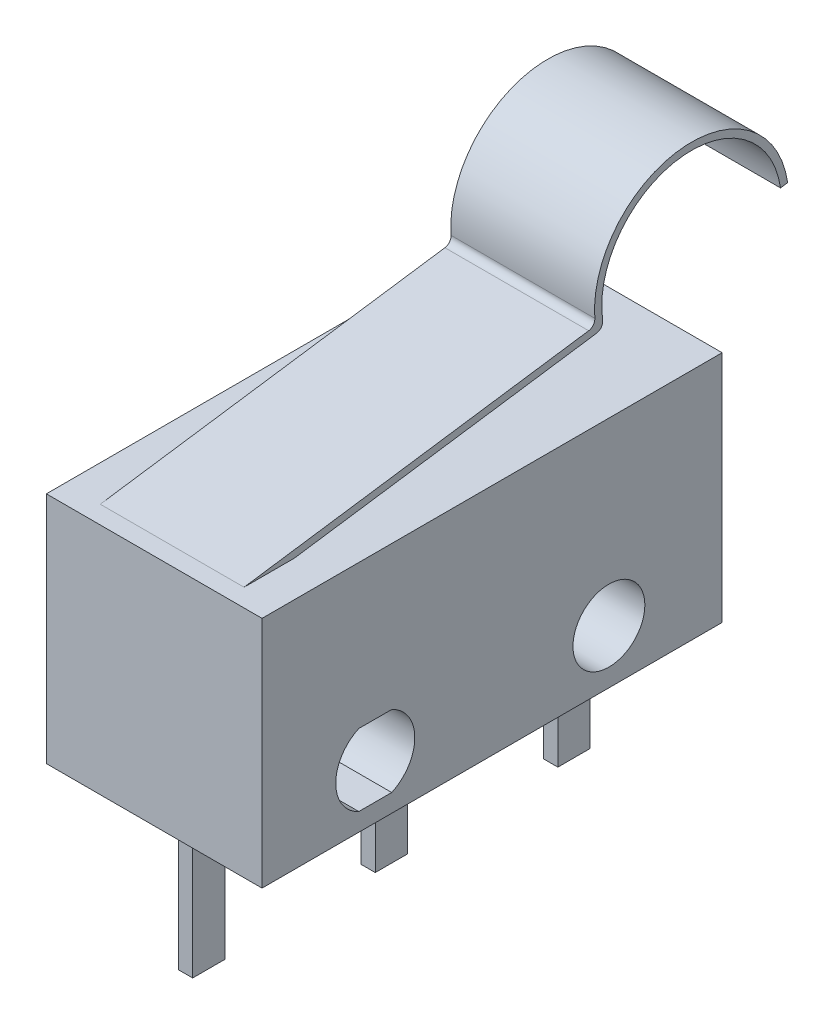
from build123d import *

# Parameters (mm, degrees)
SKETCH1_W           = 12.8
SKETCH1_H           = 6.5
SKETCH1_R           = 1
BOSS_EXTRUDE1_DEPTH = 3
SKETCH3_W           = 0.9
SKETCH3_H           = 4
BOSS_EXTRUDE2_DEPTH = 0.2
BOSS_EXTRUDE3_DEPTH = 2
FILLET1_R           = 0.2
BOSS_EXTRUDE5_DEPTH = 0.5


with BuildPart() as part:
    # Sketch1 → Boss-Extrude1 (new body, symmetric)
    with BuildSketch(Plane(origin=(0, 0, 0), x_dir=(0, 0, -1), z_dir=(1, 0, 0))):
        Rectangle(SKETCH1_W, SKETCH1_H)
        with Locations((3.25, -1.75)):
            Circle(SKETCH1_R, mode=Mode.SUBTRACT)
        with BuildLine():
            Line((-3.708257569, -0.75), (-2.791742431, -0.75))
            ThreePointArc((-2.791742431, -0.75), (-2.15, -1.75), (-2.791742431, -2.75))
            Line((-2.791742431, -2.75), (-3.708257569, -2.75))
            ThreePointArc((-3.708257569, -2.75), (-4.35, -1.75), (-3.708257569, -0.75))
        make_face(mode=Mode.SUBTRACT)
    extrude(amount=BOSS_EXTRUDE1_DEPTH, both=True)

    # Sketch3 → Boss-Extrude2 (add, symmetric)
    with BuildSketch(Plane(origin=(0, 0, 0), x_dir=(0, 0, -1), z_dir=(1, 0, 0))):
        with Locations((-5.08, -5.25)):
            Rectangle(SKETCH3_W, SKETCH3_H)
        with Locations((0, -5.25)):
            Rectangle(SKETCH3_W, SKETCH3_H)
        with Locations((5.08, -5.25)):
            Rectangle(SKETCH3_W, SKETCH3_H)
    extrude(amount=BOSS_EXTRUDE2_DEPTH, both=True)

    # Sketch4 → Boss-Extrude3 (add, symmetric)
    with BuildSketch(Plane(origin=(0, 0, 0), x_dir=(0, 0, -1), z_dir=(1, 0, 0))):
        with BuildLine():
            Line((-5.9, 3.25), (3.877784075, 4.663655529))
            ThreePointArc((3.877784075, 4.663655529), (6.163655529, 7.722215925), (9.222215925, 5.436344471))
            Line((9.222215925, 5.436344471), (9.024274005, 5.407726362))
            ThreePointArc((9.024274005, 5.407726362), (6.093510034, 7.507970079), (4.11227449, 4.495478279))
            Line((4.11227449, 4.495478279), (-4.502283608, 3.25))
            Line((-4.502283608, 3.25), (-5.9, 3.25))
        make_face()
    extrude(amount=BOSS_EXTRUDE3_DEPTH, both=True)

    # Fillet1
    fillet1_edges = [part.edges().sort_by_distance(p)[0] for p in [
        (0, 4.495478279, -4.11227449),
        (0, 4.663655529, -3.877784075),
    ]]
    fillet(fillet1_edges, radius=FILLET1_R)

    # Sketch5 → Boss-Extrude5 (add, symmetric)
    with BuildSketch(Plane(origin=(0, 0, 0), x_dir=(0, 0, -1), z_dir=(1, 0, 0))):
        with BuildLine():
            Line((-2.48, 3.25), (-1.82, 3.25))
            ThreePointArc((-1.82, 3.25), (-2.15, 3.58), (-2.48, 3.25))
        make_face()
    extrude(amount=BOSS_EXTRUDE5_DEPTH, both=True)


solid = part.part
